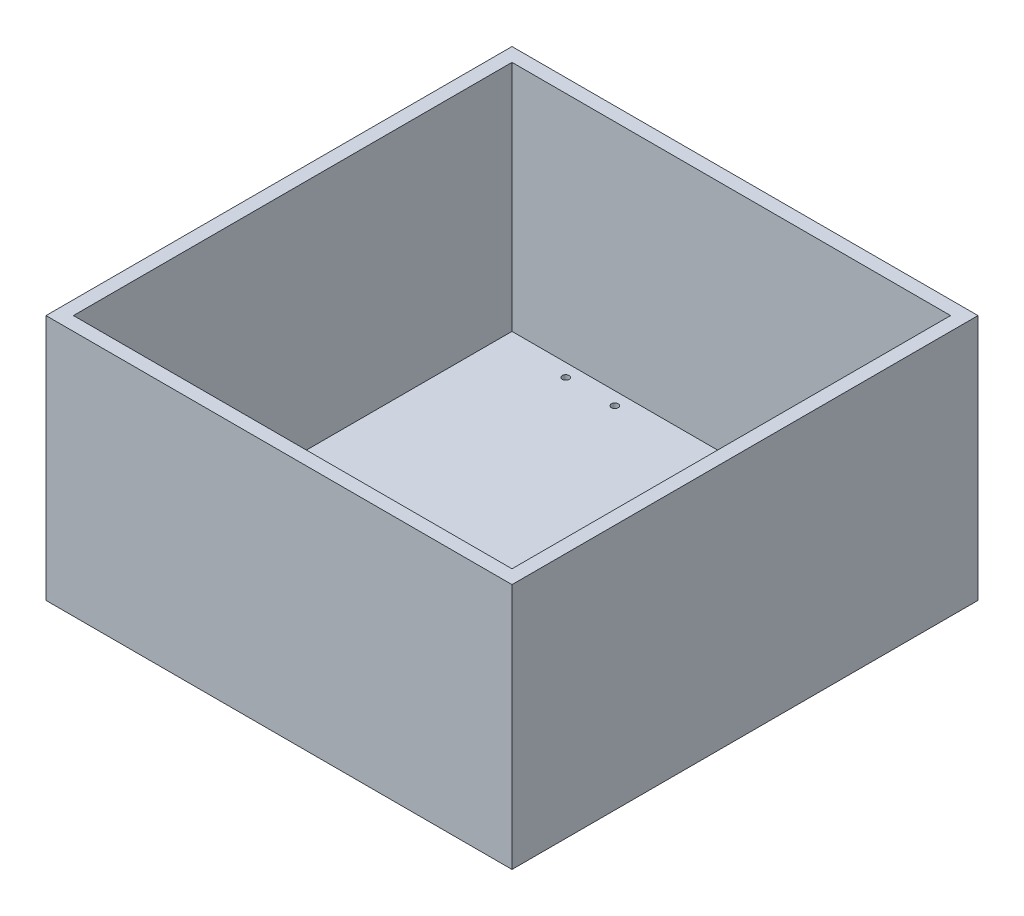
from build123d import *

# Parameters (mm, degrees)
SKETCH1_W           = 215.9
SKETCH1_H           = 215.9
BOSS_EXTRUDE1_DEPTH = 114.3
SKETCH2_W           = 203.2
SKETCH2_H           = 203.2
CUT_EXTRUDE1_DEPTH  = 107.95
MOTOR_DRIVER_R      = 1.5875
CUT_EXTRUDE4_DEPTH  = 107.95


with BuildPart() as part:
    # Sketch1 → Boss-Extrude1 (new body)
    with BuildSketch(Plane(origin=(0, 0, 0), x_dir=(1, 0, 0), z_dir=(0, 1, 0))):
        with Locations((107.95, 107.95)):
            Rectangle(SKETCH1_W, SKETCH1_H)
    extrude(amount=BOSS_EXTRUDE1_DEPTH)

    # Sketch2 → Cut-Extrude1 (cut)
    with BuildSketch(Plane(origin=(0, 114.3, 0), x_dir=(1, 0, 0), z_dir=(0, 1, 0))):
        with Locations((107.95, 107.95)):
            Rectangle(SKETCH2_W, SKETCH2_H)
    extrude(amount=-CUT_EXTRUDE1_DEPTH, mode=Mode.SUBTRACT)

    # Motor Driver → Cut-Extrude4 (cut)
    with BuildSketch(Plane(origin=(0, 6.35, 0), x_dir=(1, 0, 0), z_dir=(0, 1, 0))):
        with Locations((37.2745, 203.5175)):
            Circle(MOTOR_DRIVER_R)
        with Locations((60.0075, 203.5175)):
            Circle(MOTOR_DRIVER_R)
        with Locations((59.8805, 91.6305)):
            Circle(MOTOR_DRIVER_R)
        with Locations((37.2745, 91.6305)):
            Circle(MOTOR_DRIVER_R)
    extrude(amount=-CUT_EXTRUDE4_DEPTH, mode=Mode.SUBTRACT)


solid = part.part
